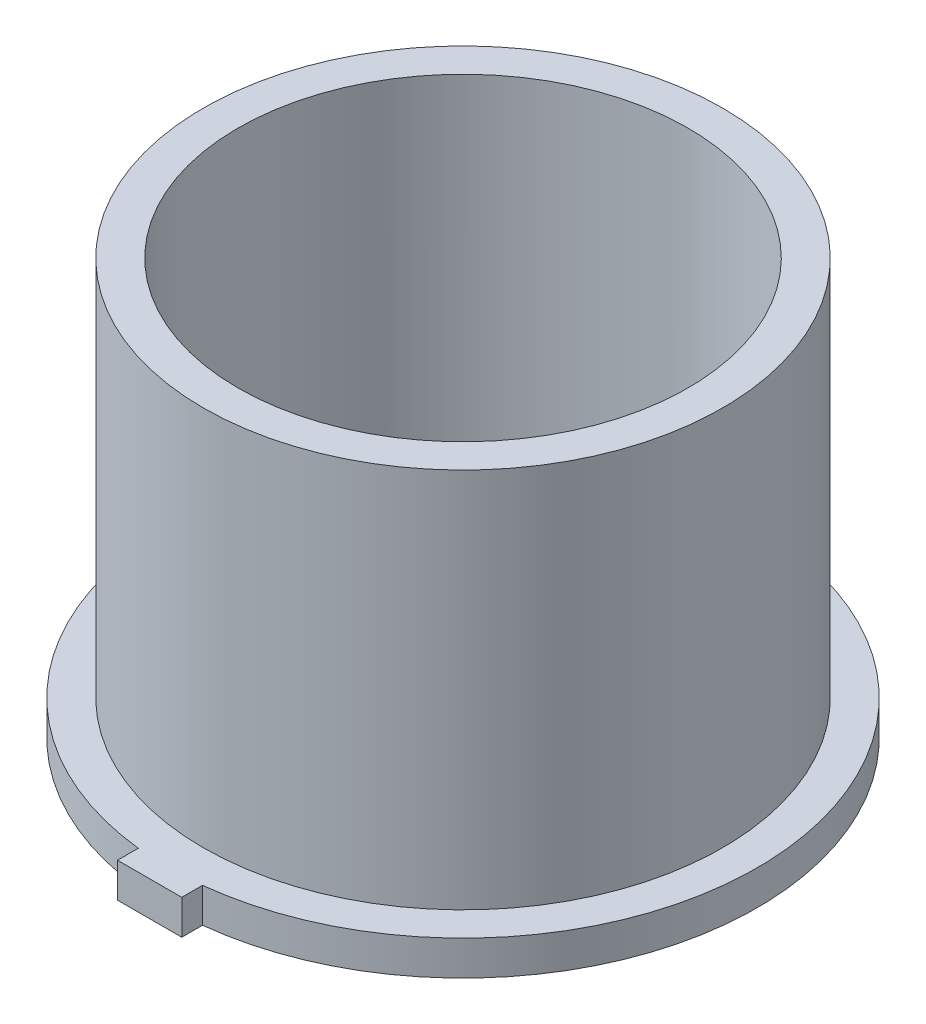
from build123d import *

# Parameters (mm, degrees)
BOSS_EXTRUDE3_DEPTH = 5
CUT_EXTRUDE1_DEPTH  = 6
SKETCH1_R           = 37.5
SKETCH1_R_2         = 32.5
BOSS_EXTRUDE4_DEPTH = 60


with BuildPart() as part:
    # Sketch4 → Boss-Extrude3 (new body)
    with BuildSketch(Plane(origin=(0, 0, 0), x_dir=(1, 0, 0), z_dir=(0, 1, 0))):
        with BuildLine():
            Line((-4.63627719, -42.246360007), (-4.63627719, -45.246360007))
            Line((-4.63627719, -45.246360007), (4.63627719, -45.246360007))
            Line((4.63627719, -45.246360007), (4.63627719, -42.246360007))
            ThreePointArc((4.63627719, -42.246360007), (42.5, 0), (4.63627719, 42.246360007))
            Line((4.63627719, 42.246360007), (4.63627719, 45.246360007))
            Line((4.63627719, 45.246360007), (-4.63627719, 45.246360007))
            Line((-4.63627719, 45.246360007), (-4.63627719, 42.246360007))
            ThreePointArc((-4.63627719, 42.246360007), (-42.5, 0), (-4.63627719, -42.246360007))
        make_face()
        with BuildLine():
            Line((-4.63627719, 32.167606902), (-4.63627719, 9))
            Line((-4.63627719, 9), (-5.196152423, 9))
            Line((-5.196152423, 9), (-10.392304845, 0))
            Line((-10.392304845, 0), (-5.196152423, -9))
            Line((-5.196152423, -9), (-4.63627719, -9))
            Line((-4.63627719, -9), (-4.63627719, -32.167606902))
            ThreePointArc((-4.63627719, -32.167606902), (-32.5, 0), (-4.63627719, 32.167606902))
        make_face(mode=Mode.SUBTRACT)
        with BuildLine():
            Line((4.63627719, 32.167606902), (4.63627719, 9))
            Line((4.63627719, 9), (5.196152423, 9))
            Line((5.196152423, 9), (10.392304845, 0))
            Line((10.392304845, 0), (5.196152423, -9))
            Line((5.196152423, -9), (4.63627719, -9))
            Line((4.63627719, -9), (4.63627719, -32.167606902))
            ThreePointArc((4.63627719, -32.167606902), (32.5, 0), (4.63627719, 32.167606902))
        make_face(mode=Mode.SUBTRACT)
    extrude(amount=BOSS_EXTRUDE3_DEPTH)

    # Sketch7 → Cut-Extrude1 (cut, through all)
    with BuildSketch(Plane(origin=(0, 0, 0), x_dir=(-1, 0, 0), z_dir=(0, -1, 0))):
        Polygon((-7.505553499, 0), (-3.75277675, -6.5), (3.75277675, -6.5), (7.505553499, 0), (3.75277675, 6.5), (-3.75277675, 6.5), align=None)
    extrude(amount=-CUT_EXTRUDE1_DEPTH, mode=Mode.SUBTRACT)

    # Sketch1 → Boss-Extrude4 (add)
    with BuildSketch(Plane(origin=(0, 0, 0), x_dir=(1, 0, 0), z_dir=(0, 1, 0))):
        Circle(SKETCH1_R)
        Circle(SKETCH1_R_2, mode=Mode.SUBTRACT)
    extrude(amount=BOSS_EXTRUDE4_DEPTH)


solid = part.part
